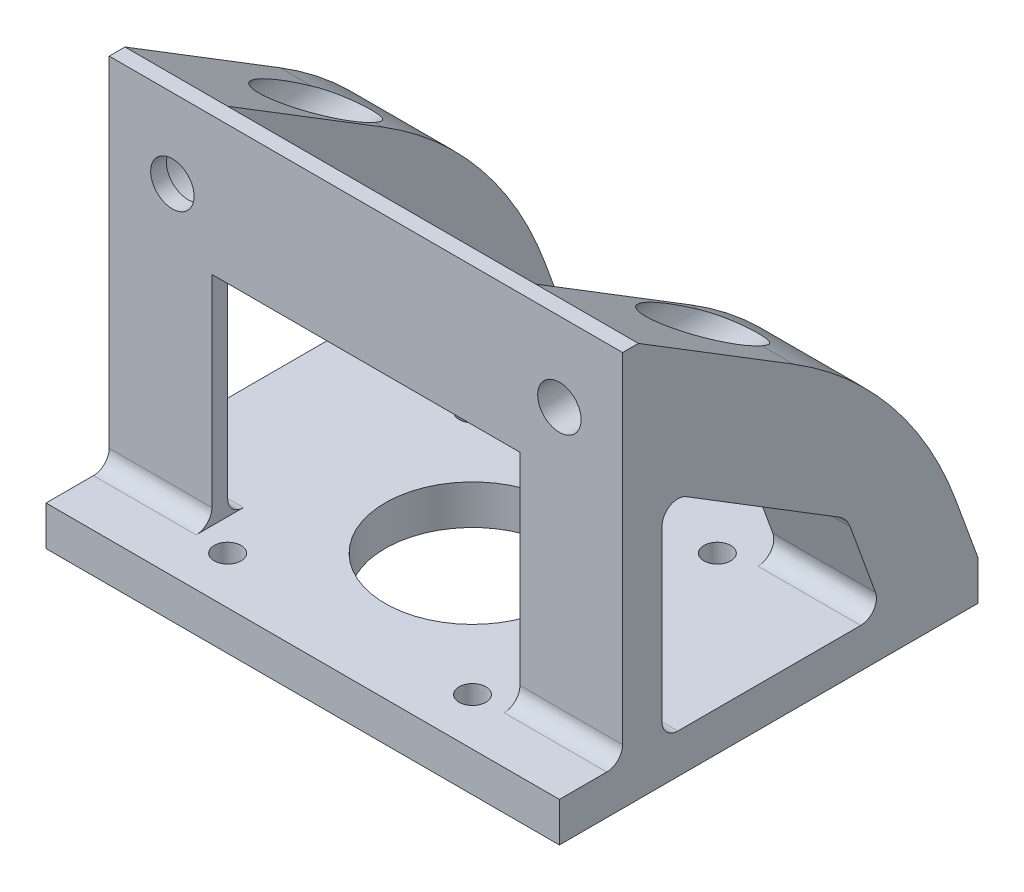
from build123d import *

# Parameters (mm, degrees)
BOSS_EXTRUDE1_DEPTH  = 32.5
SKETCH2_R            = 11.05
CUT_EXTRUDE1_DEPTH   = 43
SKETCH3_W            = 23
SKETCH3_H            = 90
CUT_EXTRUDE2_DEPTH   = 65.577472852
M5_CLEARANCE_HOLE1_D = 5.5
M3_CLEARANCE_HOLE1_D = 3.4
SKETCH9_W            = 8
SKETCH9_H            = 45
CUT_EXTRUDE3_DEPTH   = 4
SKETCH13_W           = 10
SKETCH13_H           = 5
BOSS_EXTRUDE4_DEPTH  = 65
BOSS_EXTRUDE5_START  = -13
BOSS_EXTRUDE5_DEPTH  = 13
SKETCH10_R           = 4.5
CUT_EXTRUDE4_DEPTH   = 71.215738976
BOSS_EXTRUDE6_START  = -13
BOSS_EXTRUDE6_DEPTH  = 13
FILLET1_R            = 2
SKETCH16_R           = 4.5
SKETCH16_R_2         = 2.75
BOSS_EXTRUDE7_DEPTH  = 5
SKETCH18_W           = 39
SKETCH18_H           = 17.431843069
BOSS_EXTRUDE8_DEPTH  = 2
SKETCH11_W           = 4
SKETCH11_H           = 14.485426666
CUT_EXTRUDE5_DEPTH   = 76.638945064


with BuildPart() as part:
    # Sketch1 → Boss-Extrude1 (new, symmetric)
    with BuildSketch(Plane(origin=(0, 0, 0), x_dir=(0, 0, -1), z_dir=(1, 0, 0))):
        Polygon((-11.5, 45), (-11.5, 0), (21.5, 0), (21.5, -5), (-21.5, -5), (-21.5, 0), (-13.5, 0), (-13.5, 45), align=None)
    extrude(amount=BOSS_EXTRUDE1_DEPTH, both=True)

    # Sketch2 → Cut-Extrude1 (cut)
    with BuildSketch(Plane.XZ.offset(5)):
        with Locations(Location((0, 0, 0), (0, 0, 270))):
            Circle(SKETCH2_R)
    extrude(amount=-CUT_EXTRUDE1_DEPTH, mode=Mode.SUBTRACT)

    # Sketch3 → Cut-Extrude2 (cut, through all)
    with BuildSketch(Plane(origin=(0, 0, 11.5), x_dir=(-1, 0, 0), z_dir=(0, 0, -1))):
        with Locations((0, 45)):
            Rectangle(SKETCH3_W, SKETCH3_H)
    extrude(amount=-CUT_EXTRUDE2_DEPTH, mode=Mode.SUBTRACT)

    # M5 Clearance Hole1 (through all)
    with Locations(Plane(origin=(0, 0, 11.5), x_dir=(-1, 0, 0), z_dir=(0, 0, -1))):
        with Locations((-24.5, 35), (24.5, 35)):
            Hole(M5_CLEARANCE_HOLE1_D / 2)

    # M3 Clearance Hole1 (through all)
    with Locations(Plane(origin=(0, -5, 0), x_dir=(-1, 0, 0), z_dir=(0, -1, 0))):
        with Locations((-15.5, 15.5), (15.5, 15.5), (15.5, -15.5), (-15.5, -15.5)):
            Hole(M3_CLEARANCE_HOLE1_D / 2)

    # Sketch9 → Cut-Extrude3 (cut)
    with BuildSketch(Plane(origin=(0, 0, 11.5), x_dir=(-1, 0, 0), z_dir=(0, 0, -1))):
        with Locations((-15.5, 22.5)):
            Rectangle(SKETCH9_W, SKETCH9_H)
    cut_extrude3 = extrude(amount=-CUT_EXTRUDE3_DEPTH, mode=Mode.SUBTRACT)

    # Mirror1: Cut-Extrude3 across plane
    add(cut_extrude3.mirror(Plane(origin=(0, 0, 0), x_dir=(0, 0, 1), z_dir=(1, 0, 0))), mode=Mode.SUBTRACT)

    # Sketch13 → Boss-Extrude4 (add)
    with BuildSketch(Plane.ZY.offset(32.5)):
        with Locations((-26.5, -2.5)):
            Rectangle(SKETCH13_W, SKETCH13_H)
    extrude(amount=-BOSS_EXTRUDE4_DEPTH)

    # Sketch14 → Boss-Extrude5 (add)
    with BuildSketch(Plane.ZY.offset(32.5).offset(BOSS_EXTRUDE5_START)):
        with BuildLine():
            Line((-19.5, 0), (-15.318472481, 11.488652437))
            ThreePointArc((-15.318472481, 11.488652437), (-14.742301187, 12.503177188), (-13.864717431, 13.271994839))
            Line((-13.864717431, 13.271994839), (11.5, 28.893048142))
            Line((11.5, 28.893048142), (11.5, 45))
            Line((11.5, 45), (-8.132103018, 32.909420693))
            ThreePointArc((-8.132103018, 32.909420693), (-20.553998297, 22.027072107), (-28.709504164, 7.666824297))
            Line((-28.709504164, 7.666824297), (-31.5, 0))
            Line((-31.5, 0), (-19.5, 0))
        make_face()
    boss_extrude5 = extrude(amount=BOSS_EXTRUDE5_DEPTH)

    # Mirror4: Boss-Extrude5 across plane
    add(boss_extrude5.mirror(Plane(origin=(0, 0, 0), x_dir=(0, 0, 1), z_dir=(1, 0, 0))))

    # Sketch10 → Cut-Extrude4 (cut, through all)
    with BuildSketch(Plane(origin=(0, 0, 11.5), x_dir=(-1, 0, 0), z_dir=(0, 0, -1))):
        with Locations(Location((-24.5, 35, 0), (0, 0, 207.682602444))):
            Circle(SKETCH10_R)
    cut_extrude4 = extrude(amount=CUT_EXTRUDE4_DEPTH, mode=Mode.SUBTRACT)

    # Mirror3: Cut-Extrude4 across plane
    add(cut_extrude4.mirror(Plane(origin=(0, 0, 0), x_dir=(0, 0, 1), z_dir=(1, 0, 0))), mode=Mode.SUBTRACT)

    # Sketch15 → Boss-Extrude6 (add)
    with BuildSketch(Plane(origin=(32.5, 0, 0), x_dir=(0, 0, -1), z_dir=(1, 0, 0)).offset(BOSS_EXTRUDE6_START)):
        Polygon((-11.5, 0), (-8.5, 0), (-8.5, 27.045475425), (-11.5, 28.893048142), align=None)
    extrude(amount=BOSS_EXTRUDE6_DEPTH)

    # Fillet1
    fillet1_edges = [part.edges().sort_by_distance(p)[0] for p in [
        (-26, 0, 11.5),
        (-26, 0, 13.5),
        (26, 0, 13.5),
        (-26, 0, -19.5),
        (-26, 28.893048142, 11.5),
        (26, 0, -19.5),
        (26, 27.045475425, 8.5),
        (26, 0, 8.5),
    ]]
    fillet(fillet1_edges, radius=FILLET1_R)

    # Sketch16 → Boss-Extrude7 (add)
    with BuildSketch(Plane(origin=(0, 0, 11.5), x_dir=(-1, 0, 0), z_dir=(0, 0, -1))):
        with Locations(Location((-24.5, 35, 0), (0, 0, 207.682602444))):
            Circle(SKETCH16_R)
        with Locations(Location((-24.5, 35, 0), (0, 0, 90))):
            Circle(SKETCH16_R_2, mode=Mode.SUBTRACT)
    boss_extrude7 = extrude(amount=BOSS_EXTRUDE7_DEPTH)

    # Mirror5: Boss-Extrude7 across plane
    add(boss_extrude7.mirror(Plane(origin=(0, 0, 0), x_dir=(0, 0, 1), z_dir=(1, 0, 0))))

    # Sketch18 → Boss-Extrude8 (add)
    with BuildSketch(Plane.XY.offset(13.5)):
        with Locations((0, 36.284078466)):
            Rectangle(SKETCH18_W, SKETCH18_H)
    extrude(amount=-BOSS_EXTRUDE8_DEPTH)

    # Mirror2: Cut-Extrude4 across plane
    add(cut_extrude4.mirror(Plane(origin=(0, 0, 0), x_dir=(0, 0, 1), z_dir=(1, 0, 0))), mode=Mode.SUBTRACT)

    # Sketch11 → Cut-Extrude5 (cut, through all)
    with BuildSketch(Plane(origin=(-19.5, 0, 0), x_dir=(0, 0, -1), z_dir=(1, 0, 0))):
        with Locations((9.900667288, 7.242713333)):
            Rectangle(SKETCH11_W, SKETCH11_H)
    extrude(amount=-CUT_EXTRUDE5_DEPTH, mode=Mode.SUBTRACT)


solid = part.part
